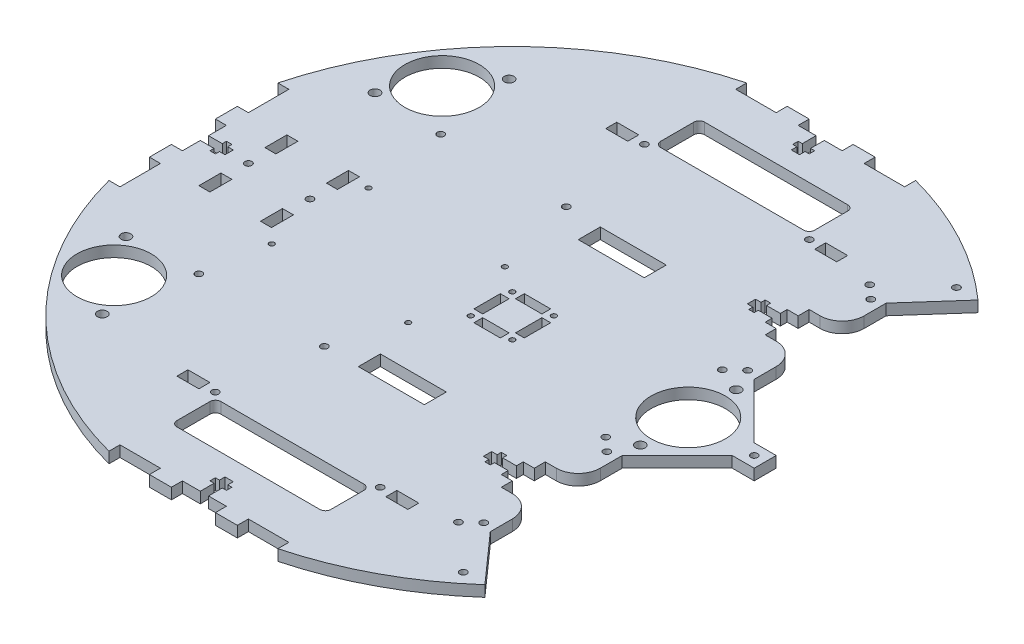
from build123d import *

# Parameters (mm, degrees)
BOSS_EXTRUDE2_DEPTH = 6.35
SKETCH18_W          = 12.7
SKETCH18_H          = 6.35
SKETCH18_R          = 2
CUT_EXTRUDE15_DEPTH = 6.35
SKETCH19_R          = 2.794
CUT_EXTRUDE16_DEPTH = 6.35
SKETCH20_R          = 2.794
SKETCH20_R_2        = 21.463
CUT_EXTRUDE17_DEPTH = 6.35
SKETCH21_W          = 3.175
SKETCH21_H          = 12.7
SKETCH21_R          = 2
SKETCH21_W_2        = 6.35
CUT_EXTRUDE18_DEPTH = 6.35
SKETCH23_R          = 2
SKETCH23_W          = 6.35
SKETCH23_H          = 12.7
CUT_EXTRUDE27_DEPTH = 6.35
SKETCH32_R          = 1.5
SKETCH32_W          = 5.08
SKETCH32_H          = 15.24
SKETCH32_W_2        = 15.24
SKETCH32_H_2        = 5.08
CUT_EXTRUDE32_DEPTH = 6.35
SKETCH33_W          = 38.1
SKETCH33_H          = 12.7
CUT_EXTRUDE33_DEPTH = 6.35
SKETCH37_R          = 1.5
CUT_EXTRUDE37_DEPTH = 6.35
SKETCH38_R          = 2
CUT_EXTRUDE38_DEPTH = 6.35
CUT_EXTRUDE30_DEPTH = 6.35
CUT_EXTRUDE31_DEPTH = 6.35
SKETCH39_R          = 2
CUT_EXTRUDE41_DEPTH = 6.35
SKETCH40_R          = 2
CUT_EXTRUDE42_DEPTH = 6.35
SKETCH41_R          = 2
CUT_EXTRUDE43_DEPTH = 6.35


with BuildPart() as part:
    # Sketch1 → Boss-Extrude2 (new body)
    with BuildSketch(Plane(origin=(0, 0, 0), x_dir=(1, 0, 0), z_dir=(0, 1, 0))):
        with BuildLine():
            Line((76.2, 82.55), (76.2, 69.85))
            Line((76.2, 69.85), (82.55, 69.85))
            Line((82.55, 69.85), (82.55, 63.5))
            Line((82.55, 63.5), (88.9, 63.5))
            ThreePointArc((88.9, 63.5), (97.880256121, 59.780256121), (101.6, 50.8))
            Line((101.6, 50.8), (101.6, 38.1))
            Line((101.6, 38.1), (127, 12.7))
            Line((127, 12.7), (133.35, 6.35))
            Line((133.35, 6.35), (146.05, 6.35))
            Line((146.05, 6.35), (146.05, -6.35))
            Line((146.05, -6.35), (133.35, -6.35))
            Line((133.35, -6.35), (127, -12.7))
            Line((127, -12.7), (101.6, -38.1))
            Line((101.6, -38.1), (101.6, -50.8))
            ThreePointArc((101.6, -50.8), (97.880256121, -59.780256121), (88.9, -63.5))
            Line((88.9, -63.5), (82.55, -63.5))
            Line((82.55, -63.5), (82.55, -69.85))
            Line((82.55, -69.85), (76.2, -69.85))
            Line((76.2, -69.85), (76.2, -82.55))
            Line((76.2, -82.55), (82.55, -82.55))
            Line((82.55, -82.55), (82.55, -88.9))
            Line((82.55, -88.9), (88.9, -88.9))
            ThreePointArc((88.9, -88.9), (97.880256121, -92.619743879), (101.6, -101.6))
            Line((101.6, -101.6), (101.6, -114.3))
            Line((101.6, -114.3), (126.561311297, -142.381475209))
            ThreePointArc((126.561311297, -142.381475209), (90.121485136, -167.834346654), (48.775275499, -184.15))
            Line((48.775275499, -184.15), (48.775275499, -177.8))
            Line((48.775275499, -177.8), (25.4, -177.8))
            Line((25.4, -177.8), (25.4, -184.15))
            Line((25.4, -184.15), (19.05, -184.15))
            Line((19.05, -184.15), (12.7, -184.15))
            Line((12.7, -184.15), (12.7, -177.8))
            Line((12.7, -177.8), (6.35, -177.8))
            Line((6.35, -177.8), (0, -177.8))
            Line((0, -177.8), (-6.35, -177.8))
            Line((-6.35, -177.8), (-12.7, -177.8))
            Line((-12.7, -177.8), (-12.7, -184.15))
            Line((-12.7, -184.15), (-19.05, -184.15))
            Line((-19.05, -184.15), (-25.4, -184.15))
            Line((-25.4, -184.15), (-25.4, -177.8))
            Line((-25.4, -177.8), (-48.775275499, -177.8))
            Line((-48.775275499, -177.8), (-48.775275499, -184.15))
            ThreePointArc((-48.775275499, -184.15), (-134.703841816, -134.703841816), (-184.15, -48.775275499))
            Line((-184.15, -48.775275499), (-177.8, -48.775275499))
            Line((-177.8, -48.775275499), (-177.8, -25.4))
            Line((-177.8, -25.4), (-184.15, -25.4))
            Line((-184.15, -25.4), (-184.15, -19.05))
            Line((-184.15, -19.05), (-184.15, -12.7))
            Line((-184.15, -12.7), (-177.8, -12.7))
            Line((-177.8, -12.7), (-177.8, -6.35))
            Line((-177.8, -6.35), (-177.8, 0))
            Line((-177.8, 0), (-177.8, 6.35))
            Line((-177.8, 6.35), (-177.8, 12.7))
            Line((-177.8, 12.7), (-184.15, 12.7))
            Line((-184.15, 12.7), (-184.15, 19.05))
            Line((-184.15, 19.05), (-184.15, 25.4))
            Line((-184.15, 25.4), (-177.8, 25.4))
            Line((-177.8, 25.4), (-177.8, 48.775275499))
            Line((-177.8, 48.775275499), (-184.15, 48.775275499))
            ThreePointArc((-184.15, 48.775275499), (-134.703841816, 134.703841816), (-48.775275499, 184.15))
            Line((-48.775275499, 184.15), (-48.775275499, 177.8))
            Line((-48.775275499, 177.8), (-25.4, 177.8))
            Line((-25.4, 177.8), (-25.4, 184.15))
            Line((-25.4, 184.15), (-19.05, 184.15))
            Line((-19.05, 184.15), (-12.7, 184.15))
            Line((-12.7, 184.15), (-12.7, 177.8))
            Line((-12.7, 177.8), (-6.35, 177.8))
            Line((-6.35, 177.8), (0, 177.8))
            Line((0, 177.8), (6.35, 177.8))
            Line((6.35, 177.8), (12.7, 177.8))
            Line((12.7, 177.8), (12.7, 184.15))
            Line((12.7, 184.15), (19.05, 184.15))
            Line((19.05, 184.15), (25.4, 184.15))
            Line((25.4, 184.15), (25.4, 177.8))
            Line((25.4, 177.8), (48.775275499, 177.8))
            Line((48.775275499, 177.8), (48.775275499, 184.15))
            ThreePointArc((48.775275499, 184.15), (90.121485136, 167.834346654), (126.561311297, 142.381475209))
            Line((126.561311297, 142.381475209), (101.6, 114.3))
            Line((101.6, 114.3), (101.6, 101.6))
            ThreePointArc((101.6, 101.6), (97.880256121, 92.619743879), (88.9, 88.9))
            Line((88.9, 88.9), (82.55, 88.9))
            Line((82.55, 88.9), (82.55, 82.55))
            Line((82.55, 82.55), (76.2, 82.55))
        make_face()
    extrude(amount=BOSS_EXTRUDE2_DEPTH)

    # Sketch18 → Cut-Extrude15 (cut)
    with BuildSketch(Plane(origin=(0, 6.35, 0), x_dir=(1, 0, 0), z_dir=(0, 1, 0))):
        with BuildLine():
            Line((0, 152.4), (-41.275, 152.4))
            ThreePointArc((-41.275, 152.4), (-43.52006403, 151.47006403), (-44.45, 149.225))
            Line((-44.45, 149.225), (-44.45, 130.175))
            ThreePointArc((-44.45, 130.175), (-43.52006403, 127.92993597), (-41.275, 127))
            Line((-41.275, 127), (0, 127))
            Line((0, 127), (0, 152.4))
        make_face()
        with BuildLine():
            Line((41.275, 152.4), (0, 152.4))
            Line((0, 152.4), (0, 127))
            Line((0, 127), (41.275, 127))
            ThreePointArc((41.275, 127), (43.52006403, 127.92993597), (44.45, 130.175))
            Line((44.45, 130.175), (44.45, 149.225))
            ThreePointArc((44.45, 149.225), (43.52006403, 151.47006403), (41.275, 152.4))
        make_face()
        with Locations((-60.325, 123.825)):
            Rectangle(SKETCH18_W, SKETCH18_H)
        with Locations((-47.625, 123.914805192)):
            Circle(SKETCH18_R)
        with Locations((60.325, 123.825)):
            Rectangle(SKETCH18_W, SKETCH18_H)
        with Locations((47.625, 123.914805192)):
            Circle(SKETCH18_R)
    cut_extrude15 = extrude(amount=-CUT_EXTRUDE15_DEPTH, mode=Mode.SUBTRACT)

    # Mirror5: Cut-Extrude15 across plane
    add(cut_extrude15.mirror(Plane.XY), mode=Mode.SUBTRACT)

    # Sketch19 → Cut-Extrude16 (cut)
    with BuildSketch(Plane(origin=(0, 6.35, 0), x_dir=(1, 0, 0), z_dir=(0, 1, 0))):
        with BuildLine():
            ThreePointArc((101.6, 21.463), (86.423367155, 15.176632845), (80.137, 0))
            Line((80.137, 0), (101.6, 0))
            Line((101.6, 0), (101.6, 21.463))
        make_face()
        with BuildLine():
            Line((101.6, 0), (80.137, 0))
            ThreePointArc((80.137, 0), (101.6, -21.463), (123.063, 0))
            ThreePointArc((123.063, 0), (116.776632845, 15.176632845), (101.6, 21.463))
            Line((101.6, 21.463), (101.6, 0))
        make_face()
        with Locations((101.6, -27.686)):
            Circle(SKETCH19_R)
        with Locations((101.6, 27.686)):
            Circle(SKETCH19_R)
    extrude(amount=-CUT_EXTRUDE16_DEPTH, mode=Mode.SUBTRACT)

    # Sketch20 → Cut-Extrude17 (cut)
    with BuildSketch(Plane(origin=(0, 6.35, 0), x_dir=(1, 0, 0), z_dir=(0, 1, 0))):
        with BuildLine():
            ThreePointArc((-122.931331459, 112.278929968), (-156.378931315, 90.970458804), (-117.660542186, 82.386798588))
            Line((-117.660542186, 82.386798588), (-135.242002512, 94.697469642))
            Line((-135.242002512, 94.697469642), (-122.931331459, 112.278929968))
        make_face()
        with BuildLine():
            Line((-135.242002512, 94.697469642), (-117.660542186, 82.386798588))
            ThreePointArc((-117.660542186, 82.386798588), (-114.772375598, 88.243421067), (-113.779002512, 94.697469642))
            ThreePointArc((-113.779002512, 94.697469642), (-116.204089, 104.607980127), (-122.931331459, 112.278929968))
            Line((-122.931331459, 112.278929968), (-135.242002512, 94.697469642))
        make_face()
        with BuildLine():
            ThreePointArc((-117.686548525, 119.769256261), (-121.5778319, 119.083118013), (-120.891693651, 115.191834638))
            Line((-120.891693651, 115.191834638), (-117.686548525, 119.769256261))
        make_face()
        with BuildLine():
            Line((-117.686548525, 119.769256261), (-120.891693651, 115.191834638))
            ThreePointArc((-120.891693651, 115.191834638), (-117.998995463, 115.002237181), (-116.495121088, 117.480545449))
            ThreePointArc((-116.495121088, 117.480545449), (-116.81081282, 118.770671075), (-117.686548525, 119.769256261))
        make_face()
        with Locations((-151.194883936, 71.914393834)):
            Circle(SKETCH20_R)
        with Locations((-135.242002512, -94.697469642)):
            Circle(SKETCH20_R_2)
        with Locations((-119.289121088, -117.480545449)):
            Circle(SKETCH20_R)
        with Locations((-151.194883936, -71.914393834)):
            Circle(SKETCH20_R)
    extrude(amount=-CUT_EXTRUDE17_DEPTH, mode=Mode.SUBTRACT)

    # Sketch21 → Cut-Extrude18 (cut)
    with BuildSketch(Plane(origin=(0, 6.35, 0), x_dir=(1, 0, 0), z_dir=(0, 1, 0))):
        with Locations((-150.8125, 19.05)):
            Rectangle(SKETCH21_W, SKETCH21_H)
        with Locations((-153.9875, 19.05)):
            Rectangle(SKETCH21_W, SKETCH21_H)
        with Locations((-152.4, 0)):
            Circle(SKETCH21_R)
        with Locations((-152.4, -19.05)):
            Rectangle(SKETCH21_W_2, SKETCH21_H)
    extrude(amount=-CUT_EXTRUDE18_DEPTH, mode=Mode.SUBTRACT)

    # Sketch23 → Cut-Extrude27 (cut)
    with BuildSketch(Plane(origin=(0, 6.35, 0), x_dir=(1, 0, 0), z_dir=(0, 1, 0))):
        with Locations((-116.84, 0)):
            Circle(SKETCH23_R)
        with Locations((-116.84, 19.05)):
            Rectangle(SKETCH23_W, SKETCH23_H)
        with Locations((-116.84, -19.05)):
            Rectangle(SKETCH23_W, SKETCH23_H)
    extrude(amount=-CUT_EXTRUDE27_DEPTH, mode=Mode.SUBTRACT)

    # Sketch32 → Cut-Extrude32 (cut)
    with BuildSketch(Plane(origin=(0, 6.35, 0), x_dir=(1, 0, 0), z_dir=(0, 1, 0))):
        with Locations((12.0015, 12.0015)):
            Circle(SKETCH32_R)
        with Locations((12.0015, -12.0015)):
            Circle(SKETCH32_R)
        with Locations((-12.0015, -12.0015)):
            Circle(SKETCH32_R)
        with Locations((-12.0015, 12.0015)):
            Circle(SKETCH32_R)
        with Locations((12.0015, 0)):
            Rectangle(SKETCH32_W, SKETCH32_H)
        with Locations((0, 12.0015)):
            Rectangle(SKETCH32_W_2, SKETCH32_H_2)
        with Locations((0, -12.0015)):
            Rectangle(SKETCH32_W_2, SKETCH32_H_2)
        with Locations((-12.0015, 0)):
            Rectangle(SKETCH32_W, SKETCH32_H)
    extrude(amount=-CUT_EXTRUDE32_DEPTH, mode=Mode.SUBTRACT)

    # Sketch33 → Cut-Extrude33 (cut)
    with BuildSketch(Plane(origin=(0, 6.35, 0), x_dir=(1, 0, 0), z_dir=(0, 1, 0))):
        with Locations((0, 63.5)):
            Rectangle(SKETCH33_W, SKETCH33_H)
        with Locations((0, -63.5)):
            Rectangle(SKETCH33_W, SKETCH33_H)
    extrude(amount=-CUT_EXTRUDE33_DEPTH, mode=Mode.SUBTRACT)

    # Sketch37 → Cut-Extrude37 (cut)
    with BuildSketch(Plane(origin=(0, 6.35, 0), x_dir=(1, 0, 0), z_dir=(0, 1, 0))):
        with Locations((-105.418304402, 22.394205224)):
            Circle(SKETCH37_R)
        with Locations((-26.678304402, 22.394205224)):
            Circle(SKETCH37_R)
        with Locations((-26.678304402, -33.485794776)):
            Circle(SKETCH37_R)
        with Locations((-105.418304402, -33.485794776)):
            Circle(SKETCH37_R)
    extrude(amount=-CUT_EXTRUDE37_DEPTH, mode=Mode.SUBTRACT)

    # Sketch38 → Cut-Extrude38 (cut)
    with BuildSketch(Plane(origin=(0, 6.35, 0), x_dir=(1, 0, 0), z_dir=(0, 1, 0))):
        with Locations((-39.005400394, 70.156955464)):
            Circle(SKETCH38_R)
        with Locations((-111.505400394, 70.156955464)):
            Circle(SKETCH38_R)
        with Locations((-111.505400394, -69.543044536)):
            Circle(SKETCH38_R)
        with Locations((-39.005400394, -69.543044536)):
            Circle(SKETCH38_R)
    extrude(amount=-CUT_EXTRUDE38_DEPTH, mode=Mode.SUBTRACT)

    # Sketch27 → Cut-Extrude30 (cut)
    with BuildSketch(Plane(origin=(0, 6.35, 0), x_dir=(1, 0, 0), z_dir=(0, 1, 0))):
        Polygon((76.2, 73.81875), (76.2, 78.58125), (68.2625, 78.58125), (68.2625, 80.9625), (65.0875, 80.9625), (65.0875, 78.58125), (61.9125, 78.58125), (61.9125, 73.81875), (65.0875, 73.81875), (65.0875, 71.4375), (68.2625, 71.4375), (68.2625, 73.81875), align=None)
        Polygon((76.2, -73.81875), (68.2625, -73.81875), (68.2625, -71.4375), (65.0875, -71.4375), (65.0875, -73.81875), (61.9125, -73.81875), (61.9125, -78.58125), (65.0875, -78.58125), (65.0875, -80.9625), (68.2625, -80.9625), (68.2625, -78.58125), (76.2, -78.58125), align=None)
    extrude(amount=-CUT_EXTRUDE30_DEPTH, mode=Mode.SUBTRACT)

    # Sketch29 → Cut-Extrude31 (cut)
    with BuildSketch(Plane(origin=(0, 6.35, 0), x_dir=(1, 0, 0), z_dir=(0, 1, 0))):
        Polygon((-2.38125, 177.8), (2.38125, 177.8), (2.38125, 169.8625), (4.7625, 169.8625), (4.7625, 166.6875), (2.38125, 166.6875), (2.38125, 163.5125), (-2.38125, 163.5125), (-2.38125, 166.6875), (-4.7625, 166.6875), (-4.7625, 169.8625), (-2.38125, 169.8625), align=None)
        Polygon((-177.8, -2.38125), (-177.8, 2.38125), (-169.8625, 2.38125), (-169.8625, 4.7625), (-166.6875, 4.7625), (-166.6875, 2.38125), (-163.5125, 2.38125), (-163.5125, -2.38125), (-166.6875, -2.38125), (-166.6875, -4.7625), (-169.8625, -4.7625), (-169.8625, -2.38125), align=None)
        Polygon((2.38125, -177.8), (-2.38125, -177.8), (-2.38125, -169.8625), (-4.7625, -169.8625), (-4.7625, -166.6875), (-2.38125, -166.6875), (-2.38125, -163.5125), (2.38125, -163.5125), (2.38125, -166.6875), (4.7625, -166.6875), (4.7625, -169.8625), (2.38125, -169.8625), align=None)
    extrude(amount=-CUT_EXTRUDE31_DEPTH, mode=Mode.SUBTRACT)

    # Sketch39 → Cut-Extrude41 (cut)
    with BuildSketch(Plane(origin=(0, 6.35, 0), x_dir=(1, 0, 0), z_dir=(0, 1, 0))):
        with Locations((87.63, 33.655)):
            Circle(SKETCH39_R)
        with Locations((95.25, 40.64)):
            Circle(SKETCH39_R)
        with Locations((95.25, -111.76)):
            Circle(SKETCH39_R)
        with Locations((87.63, -118.745)):
            Circle(SKETCH39_R)
        with Locations((87.63, 118.745)):
            Circle(SKETCH39_R)
        with Locations((95.25, 111.76)):
            Circle(SKETCH39_R)
        with Locations((95.25, -40.64)):
            Circle(SKETCH39_R)
        with Locations((87.63, -33.655)):
            Circle(SKETCH39_R)
    extrude(amount=-CUT_EXTRUDE41_DEPTH, mode=Mode.SUBTRACT)

    # Sketch40 → Cut-Extrude42 (cut)
    with BuildSketch(Plane(origin=(0, 6.35, 0), x_dir=(1, 0, 0), z_dir=(0, 1, 0))):
        with Locations((139.7, 0)):
            Circle(SKETCH40_R)
    extrude(amount=-CUT_EXTRUDE42_DEPTH, mode=Mode.SUBTRACT)

    # Sketch41 → Cut-Extrude43 (cut)
    with BuildSketch(Plane(origin=(0, 6.35, 0), x_dir=(1, 0, 0), z_dir=(0, 1, 0))):
        with Locations((114.080655649, 142.381475209)):
            Circle(SKETCH41_R)
        with Locations((114.080655649, -142.381475209)):
            Circle(SKETCH41_R)
    extrude(amount=-CUT_EXTRUDE43_DEPTH, mode=Mode.SUBTRACT)


solid = part.part
